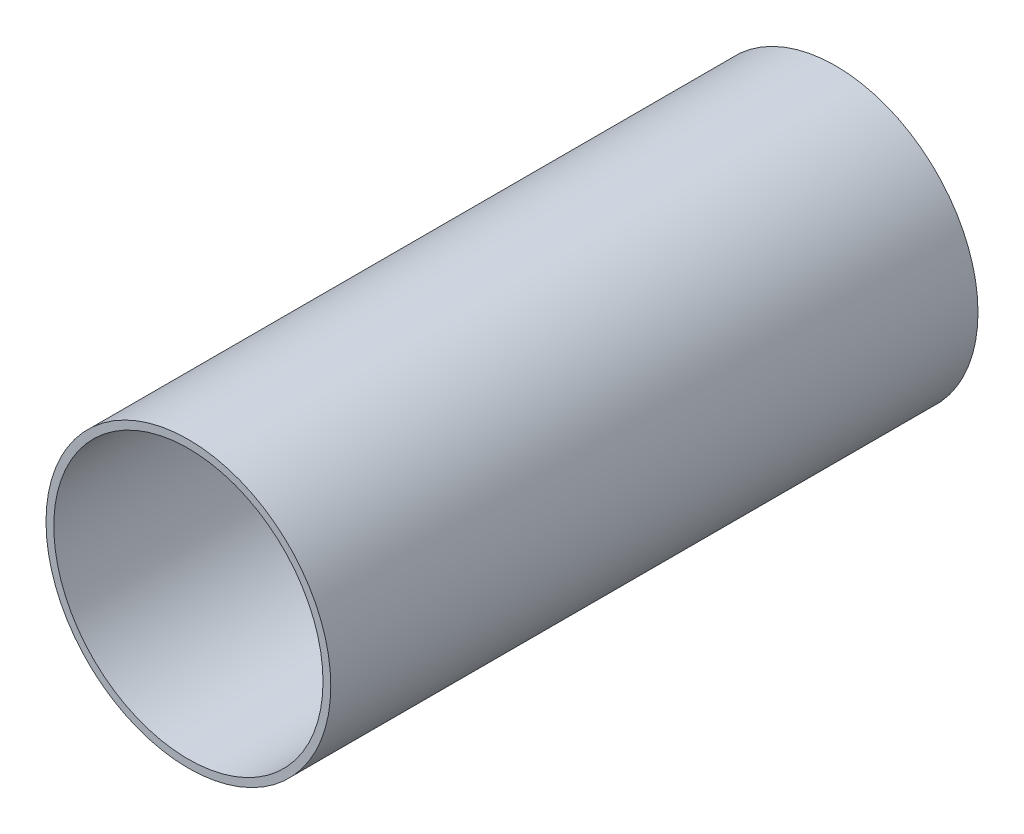
from build123d import *

# Parameters (mm, degrees)
SKETCH_2_R      = 55
SKETCH_2_R_2    = 52
EXTRUDE_1_DEPTH = 250


with BuildPart() as part:
    # 草图2 → 凸台-拉伸1 (new body)
    with BuildSketch(Plane.XY):
        Circle(SKETCH_2_R)
        Circle(SKETCH_2_R_2, mode=Mode.SUBTRACT)
    extrude(amount=EXTRUDE_1_DEPTH)


solid = part.part
